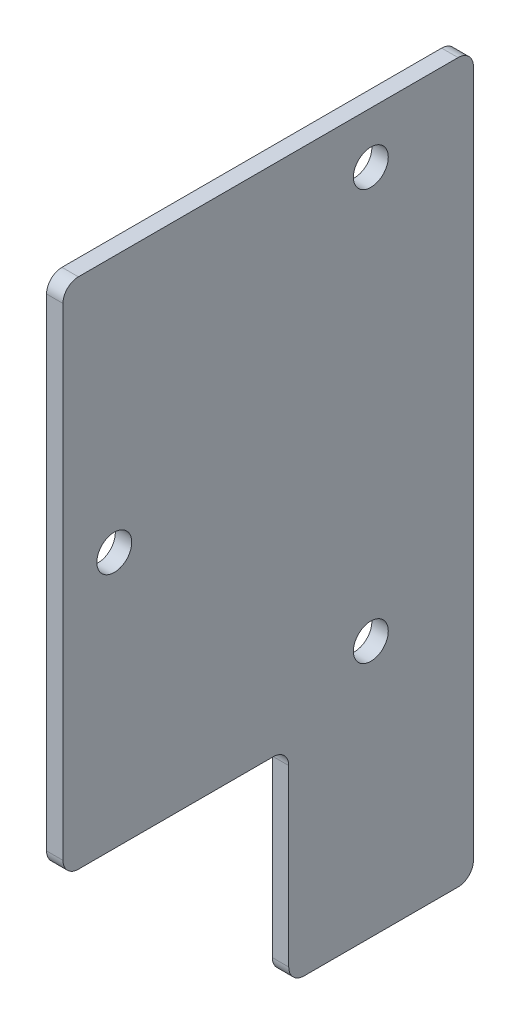
from build123d import *

# Parameters (mm, degrees)
BOSS_EXTRUDE1_DEPTH      = 1.6002
M3_CLEARANCE_HOLE1_D     = 3.4
M3_CLEARANCE_HOLE1_DEPTH = 6
M3_CLEARANCE_HOLE1_TIP   = 1.021463052
FILLET1_R                = 1.5


with BuildPart() as part:
    # Sketch1 → Boss-Extrude1 (new body)
    with BuildSketch(Plane(origin=(0, 0, 0), x_dir=(0, 0, -1), z_dir=(1, 0, 0))):
        Polygon((-20, 25), (20, 25), (20, -25), (20, -45), (2, -45), (2, -25), (-20, -25), align=None)
    extrude(amount=BOSS_EXTRUDE1_DEPTH)

    # M3 Clearance Hole1
    with Locations(Plane(origin=(1.6002, 0, 0), x_dir=(0, 0, -1), z_dir=(1, 0, 0))):
        with Locations((10, 20), (10, -20), (-15, 0)):
            Hole(M3_CLEARANCE_HOLE1_D / 2, depth=M3_CLEARANCE_HOLE1_DEPTH)
            with Locations((0, 0, -(M3_CLEARANCE_HOLE1_DEPTH + M3_CLEARANCE_HOLE1_TIP / 2))):  # 118° drill point
                Cone(0, M3_CLEARANCE_HOLE1_D / 2, M3_CLEARANCE_HOLE1_TIP, mode=Mode.SUBTRACT)

    # Fillet1
    fillet1_edges = [part.edges().sort_by_distance(p)[0] for p in [
        (0.8001, -45, -20),
        (0.8001, -45, -2),
        (0.8001, -25, -2),
        (0.8001, -25, 20),
        (0.8001, 25, 20),
        (0.8001, 25, -20),
    ]]
    fillet(fillet1_edges, radius=FILLET1_R)


solid = part.part
